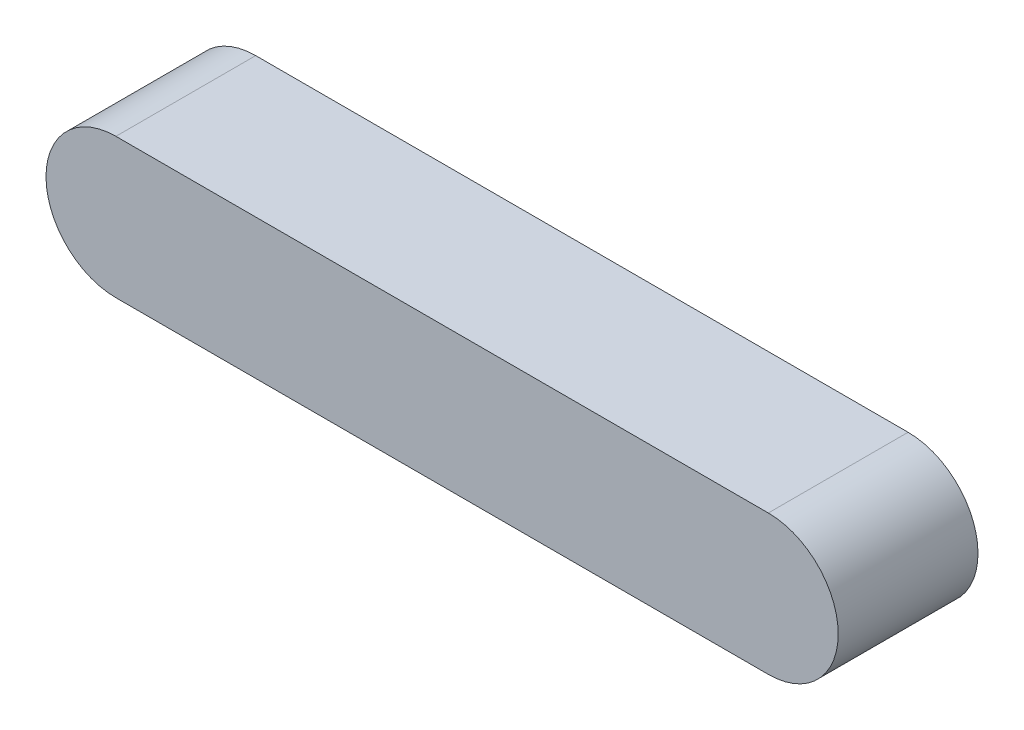
from build123d import *

# Parameters (mm, degrees)
EXTRUDE_1_DEPTH = 15


with BuildPart() as part:
    # 草图1 → 凸台-拉伸1 (new body)
    with BuildSketch(Plane.XY):
        with BuildLine():
            Line((0, 0), (70, 0))
            ThreePointArc((70, 0), (77.5, 7.5), (70, 15))
            Line((70, 15), (0, 15))
            ThreePointArc((0, 15), (-7.5, 7.5), (0, 0))
        make_face()
    extrude(amount=EXTRUDE_1_DEPTH)


solid = part.part
